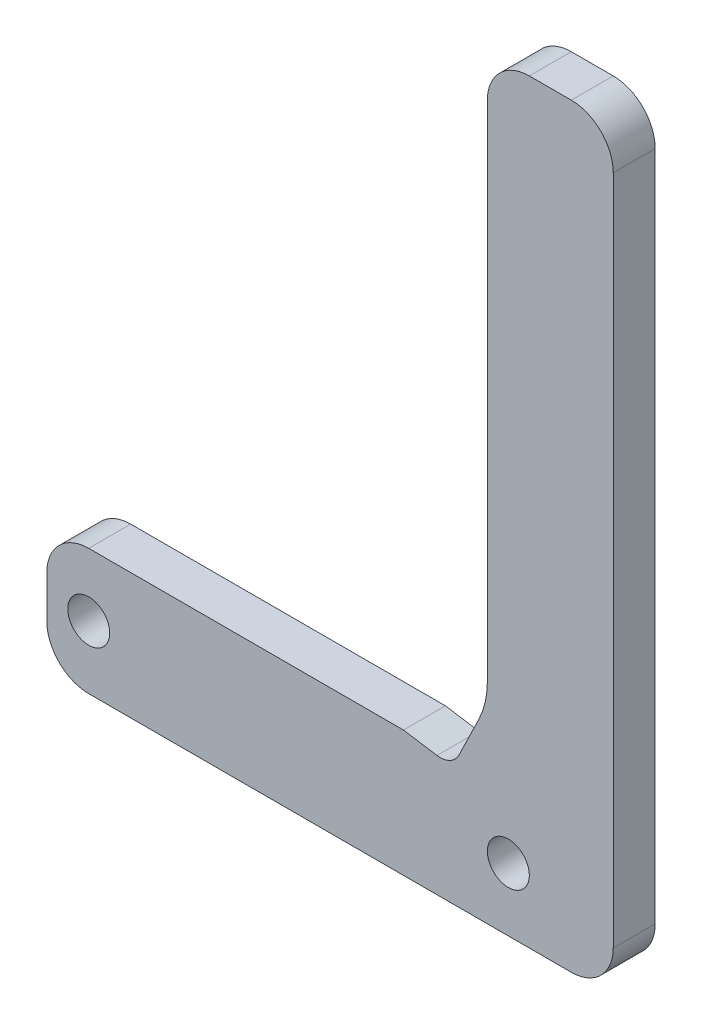
from build123d import *

# Parameters (mm, degrees)
SKETCH1_R           = 3.175
BOSS_EXTRUDE1_DEPTH = 6.35
FILLET1_R           = 6.35
FILLET2_R           = 12.7
CUT_EXTRUDE1_DEPTH  = 7.35


with BuildPart() as part:
    # Sketch1 → Boss-Extrude1 (new body)
    with BuildSketch(Plane.XY):
        Polygon((0, 19.05), (0, 0), (85.725, 0), (85.725, 114.3), (66.675, 114.3), (66.675, 19.05), align=None)
        with Locations((69.85, 9.525)):
            Circle(SKETCH1_R, mode=Mode.SUBTRACT)
        with Locations((6.35, 9.525)):
            Circle(SKETCH1_R, mode=Mode.SUBTRACT)
    extrude(amount=BOSS_EXTRUDE1_DEPTH)

    # Fillet1
    fillet1_edges = [part.edges().sort_by_distance(p)[0] for p in [
        (66.675, 114.3, 3.175),
        (85.725, 114.3, 3.175),
        (85.725, 0, 3.175),
        (0, 0, 3.175),
        (0, 19.05, 3.175),
    ]]
    fillet(fillet1_edges, radius=FILLET1_R)

    # Fillet2
    fillet2_edges = [part.edges().sort_by_distance(p)[0] for p in [
        (66.675, 19.05, 3.175),
    ]]
    fillet(fillet2_edges, radius=FILLET2_R)

    # Sketch2 → Cut-Extrude1 (cut, through all)
    with BuildSketch(Plane.XY.offset(6.35)):
        with BuildLine():
            Line((53.975, 19.05), (59.055, 18.25625))
            ThreePointArc((59.055, 18.25625), (57.942186014, 18.652541864), (57.051260526, 19.42820544))
            ThreePointArc((57.051260526, 19.42820544), (55.524711116, 19.144905972), (53.975, 19.05))
        make_face()
        with BuildLine():
            ThreePointArc((57.051260526, 19.42820544), (57.942186014, 18.652541864), (59.055, 18.25625))
            ThreePointArc((59.055, 18.25625), (61.018534307, 18.580759781), (62.403160549, 20.010299477))
            ThreePointArc((62.403160549, 20.010299477), (62.639885623, 20.683811475), (62.720146595, 21.393188207))
            ThreePointArc((62.720146595, 21.393188207), (62.67970364, 21.89833881), (62.559405095, 22.390620257))
            ThreePointArc((62.559405095, 22.390620257), (59.990542874, 20.565043856), (57.051260526, 19.42820544))
        make_face()
        with BuildLine():
            ThreePointArc((62.720146595, 21.393188207), (62.639885623, 20.683811475), (62.403160549, 20.010299477))
            Line((62.403160549, 20.010299477), (65.407055815, 26.21844508))
            ThreePointArc((65.407055815, 26.21844508), (64.164589666, 24.169613306), (62.559405095, 22.390620257))
            ThreePointArc((62.559405095, 22.390620257), (62.67970364, 21.89833881), (62.720146595, 21.393188207))
        make_face()
    extrude(amount=-CUT_EXTRUDE1_DEPTH, mode=Mode.SUBTRACT)


solid = part.part
